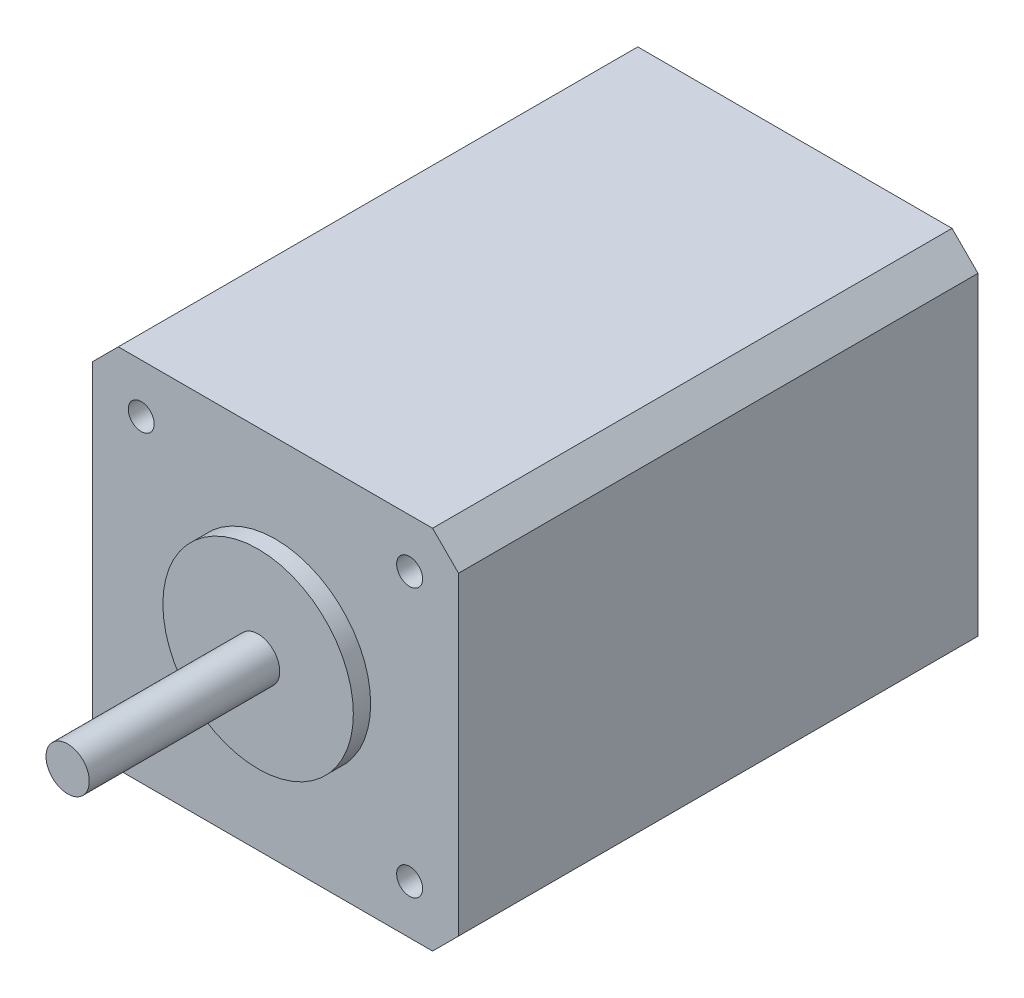
from build123d import *

# Parameters (mm, degrees)
SKETCH_1_W                = 42.3
SKETCH_1_H                = 60
EXTRUDE_1_DEPTH           = 42.3
HOLE_WIZARD_3_0_3_1_D     = 3
HOLE_WIZARD_3_0_3_1_DEPTH = 5
CHAMFER_1_SIZE            = 3


with BuildPart() as part:
    # 草图1 → 凸台-拉伸1 (new body)
    with BuildSketch(Plane.XZ.offset(21.15)):
        with Locations((0, 25)):
            Rectangle(SKETCH_1_W, SKETCH_1_H)
    extrude(amount=-EXTRUDE_1_DEPTH)

    # 草图2 → 旋转1 (revolve)
    with BuildSketch(Plane.XZ):
        Polygon((2.5, 79), (0, 79), (0, 55), (11, 55), (11, 57), (2.5, 57), align=None)
    revolve(axis=Axis((0, 0, 79), (0, 0, -1)))

    # Ø3.0 (3) 直径孔1
    with Locations(Plane.XY.offset(55)):
        with Locations((15.5, -15.5), (-15.5, -15.5), (-15.5, 15.5), (15.5, 15.5)):
            Hole(HOLE_WIZARD_3_0_3_1_D / 2, depth=HOLE_WIZARD_3_0_3_1_DEPTH)

    # 倒角1
    chamfer_1_edges = [part.edges().sort_by_distance(p)[0] for p in [
        (-21.15, 21.15, 25),
        (21.15, 21.15, 25),
        (-21.15, -21.15, 25),
        (21.15, -21.15, 25),
    ]]
    chamfer(chamfer_1_edges, length=CHAMFER_1_SIZE)


solid = part.part
